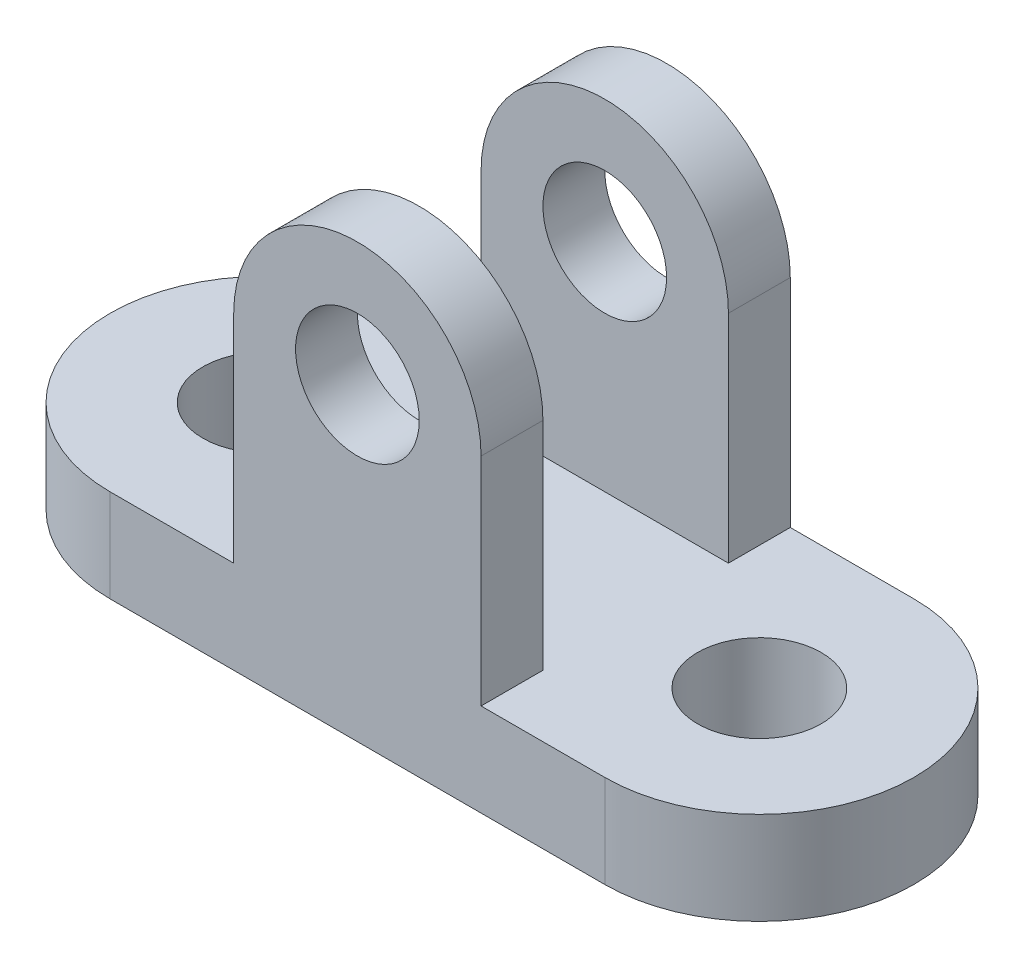
from build123d import *

# Parameters (mm, degrees)
SKETCH1_R           = 10
BOSS_EXTRUDE1_DEPTH = 15
SKETCH2_R           = 10
BOSS_EXTRUDE2_DEPTH = 50
SKETCH3_W           = 58.079398224
SKETCH3_H           = 30
CUT_EXTRUDE1_DEPTH  = 56


with BuildPart() as part:
    # Sketch1 → Boss-Extrude1 (new body)
    with BuildSketch(Plane(origin=(0, 0, 0), x_dir=(1, 0, 0), z_dir=(0, 1, 0))):
        with BuildLine():
            Line((-40, 25), (40, 25))
            ThreePointArc((40, 25), (65, 0), (40, -25))
            Line((40, -25), (-40, -25))
            ThreePointArc((-40, -25), (-65, 0), (-40, 25))
        make_face()
        with Locations((-40, 0)):
            Circle(SKETCH1_R, mode=Mode.SUBTRACT)
        with Locations((40, 0)):
            Circle(SKETCH1_R, mode=Mode.SUBTRACT)
    extrude(amount=BOSS_EXTRUDE1_DEPTH)

    # Sketch2 → Boss-Extrude2 (add)
    with BuildSketch(Plane.XY.offset(25)):
        with BuildLine():
            ThreePointArc((20, 50), (0, 70), (-20, 50))
            Line((-20, 50), (-20, 0))
            Line((-20, 0), (20, 0))
            Line((20, 0), (20, 50))
        make_face()
        with Locations((0, 50)):
            Circle(SKETCH2_R, mode=Mode.SUBTRACT)
    extrude(amount=-BOSS_EXTRUDE2_DEPTH)

    # Sketch3 → Cut-Extrude1 (cut, through all)
    with BuildSketch(Plane(origin=(0, 15, 0), x_dir=(1, 0, 0), z_dir=(0, 1, 0))):
        Rectangle(SKETCH3_W, SKETCH3_H)
    extrude(amount=CUT_EXTRUDE1_DEPTH, mode=Mode.SUBTRACT)


solid = part.part
